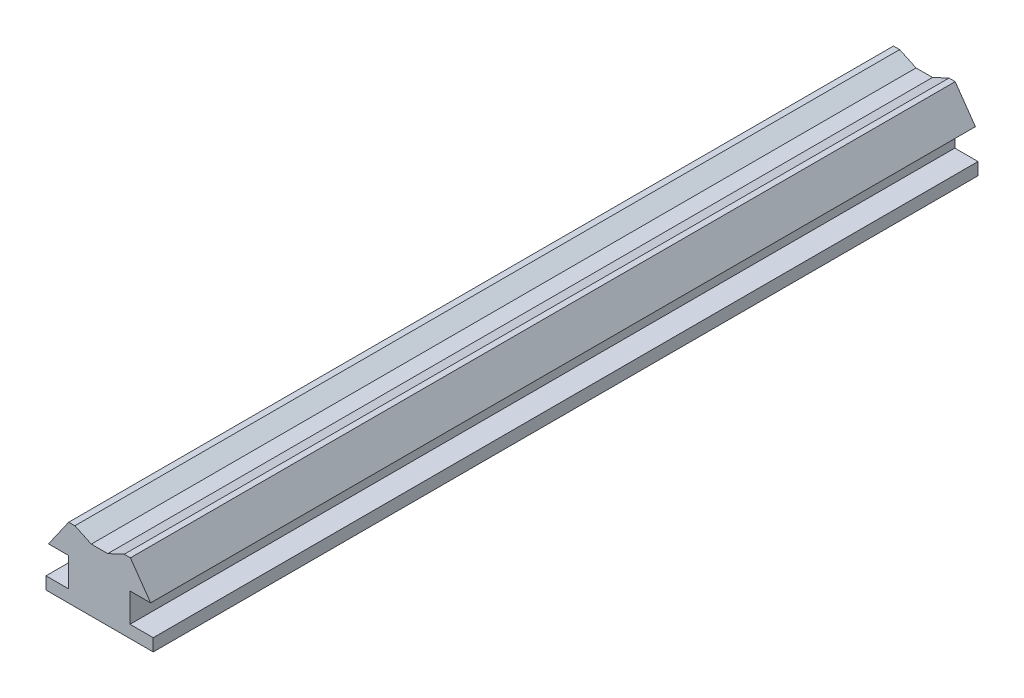
from build123d import *

# Parameters (mm, degrees)
BOSS_EXTRUDE3_DEPTH = 2000


with BuildPart() as part:
    # Sketch2 → Boss-Extrude3 (new body)
    with BuildSketch(Plane.XY):
        Polygon((-50.222128044, 71.120657772), (-90.050058891, 89.692726934), (-105.050058891, 89.692726934), (-154.090844199, 19.655227147), (-105.210977603, 19.655227147), (-105.210977603, 14.334338285), (-105.210977603, -50.344772853), (-160.050058891, -50.344772853), (-160.050058891, -59.624830396), (-160.050058891, -80.344772853), (99.949941109, -80.344772853), (99.949941109, -50.344772853), (43.668796434, -50.344772853), (43.668796434, 19.655227147), (93.668796434, 19.655227147), (44.605802804, 89.724443705), (29.605802804, 89.724443705), (-10.290144877, 71.120657772), align=None)
    extrude(amount=BOSS_EXTRUDE3_DEPTH)


solid = part.part
